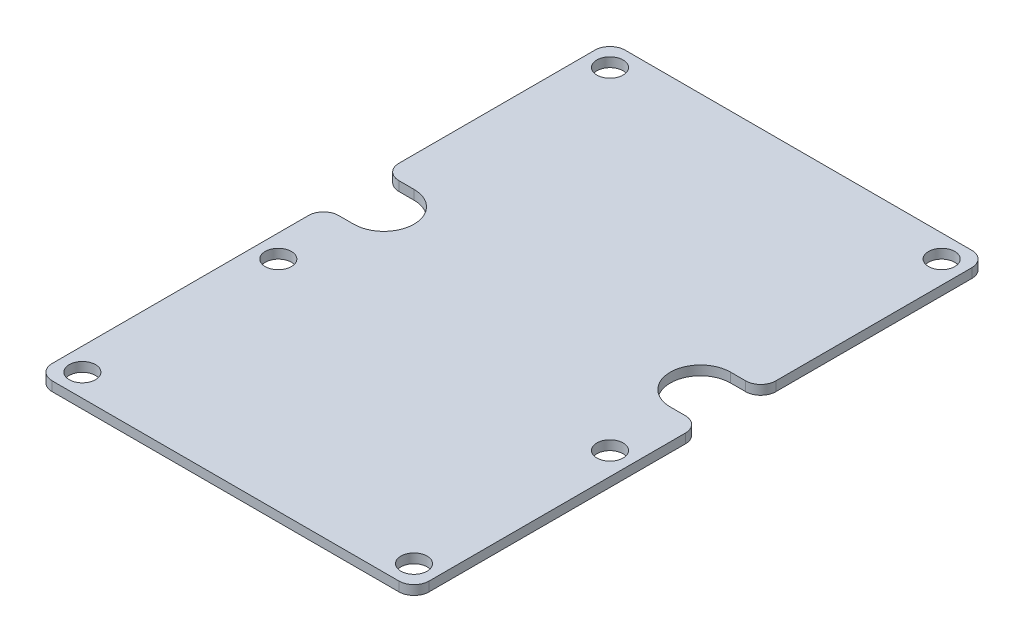
from build123d import *

# Parameters (mm, degrees)
BOSS_EXTRUDE1_DEPTH = 1.5875
SKETCH5_R           = 2.2098
CUT_EXTRUDE1_DEPTH  = 2.5875


with BuildPart() as part:
    # Sketch4 → Boss-Extrude1 (new body)
    with BuildSketch(Plane(origin=(0, 0, 0), x_dir=(1, 0, 0), z_dir=(0, 1, 0))):
        with BuildLine():
            Line((-29.21, 76.2), (29.21, 76.2))
            ThreePointArc((29.21, 76.2), (31.006051224, 75.456051224), (31.75, 73.66))
            Line((31.75, 73.66), (31.75, 40.64))
            ThreePointArc((31.75, 40.64), (31.006051224, 38.843948776), (29.21, 38.1))
            Line((29.21, 38.1), (26.67, 38.1))
            ThreePointArc((26.67, 38.1), (21.59, 33.02), (26.67, 27.94))
            Line((26.67, 27.94), (29.21, 27.94))
            ThreePointArc((29.21, 27.94), (31.006051224, 27.196051224), (31.75, 25.4))
            Line((31.75, 25.4), (31.75, -17.78))
            ThreePointArc((31.75, -17.78), (31.006051224, -19.576051224), (29.21, -20.32))
            Line((29.21, -20.32), (-29.21, -20.32))
            ThreePointArc((-29.21, -20.32), (-31.006051224, -19.576051224), (-31.75, -17.78))
            Line((-31.75, -17.78), (-31.75, 25.4))
            ThreePointArc((-31.75, 25.4), (-31.006051224, 27.196051224), (-29.21, 27.94))
            Line((-29.21, 27.94), (-26.67, 27.94))
            ThreePointArc((-26.67, 27.94), (-21.59, 33.02), (-26.67, 38.1))
            Line((-26.67, 38.1), (-29.21, 38.1))
            ThreePointArc((-29.21, 38.1), (-31.006051224, 38.843948776), (-31.75, 40.64))
            Line((-31.75, 40.64), (-31.75, 73.66))
            ThreePointArc((-31.75, 73.66), (-31.006051224, 75.456051224), (-29.21, 76.2))
        make_face()
    extrude(amount=-BOSS_EXTRUDE1_DEPTH)

    # Sketch5 → Cut-Extrude1 (cut, through all)
    with BuildSketch(Plane(origin=(0, 0, 0), x_dir=(1, 0, 0), z_dir=(0, 1, 0))):
        with Locations((-27.94, 72.39)):
            Circle(SKETCH5_R)
        with Locations((27.94, 72.39)):
            Circle(SKETCH5_R)
        with Locations((-27.94, -16.51)):
            Circle(SKETCH5_R)
        with Locations((27.94, -16.51)):
            Circle(SKETCH5_R)
        with Locations((-27.94, 16.51)):
            Circle(SKETCH5_R)
        with Locations((27.94, 16.51)):
            Circle(SKETCH5_R)
    extrude(amount=-CUT_EXTRUDE1_DEPTH, mode=Mode.SUBTRACT)


solid = part.part
